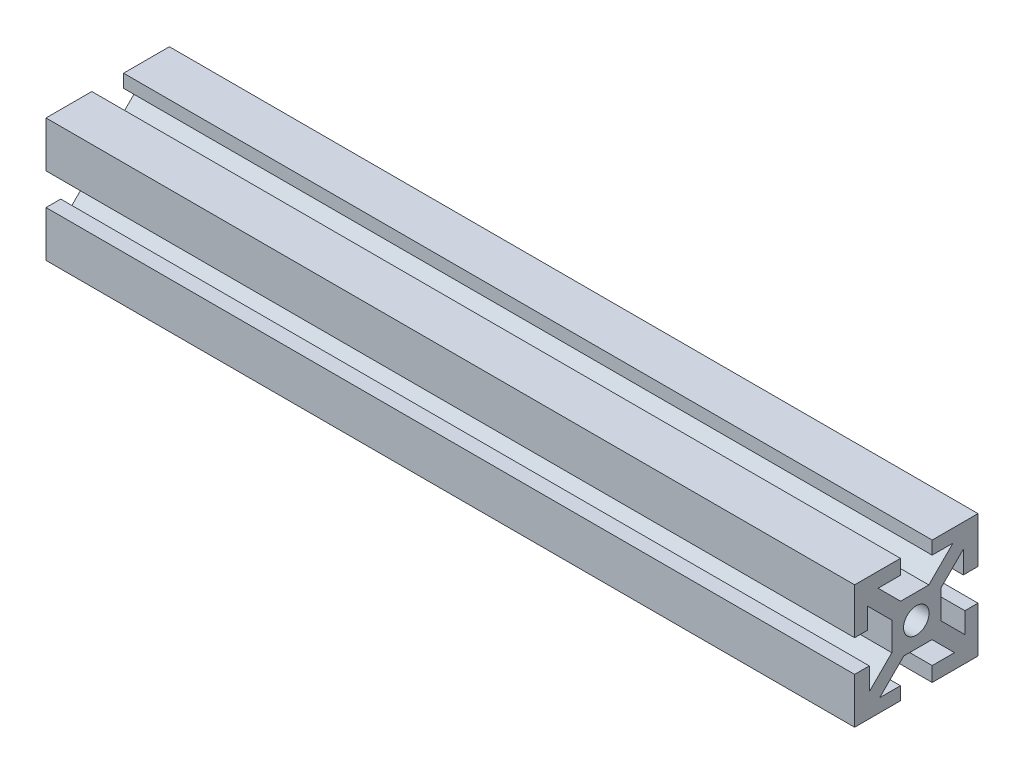
from build123d import *

# Parameters (mm, degrees)
SKETCH1_R           = 2.605
BOSS_EXTRUDE1_DEPTH = 165.1
CIRPATTERN1_COUNT   = 4
SKETCH2_R           = 2.38
CUT_EXTRUDE6_DEPTH  = 8


with BuildPart() as part:
    # Sketch1 → Boss-Extrude1 (new body)
    with BuildSketch(Plane(origin=(0, 0, 0), x_dir=(0, 0, -1), z_dir=(1, 0, 0))):
        Polygon((5, -5), (5, 3.203948776), (9.596194078, 7.800142853), (9.596194078, 3.24), (12.596194078, 3.24), (12.596194078, 12.596194078), (3.24, 12.596194078), (3.24, 9.921463197), (7.474873734, 9.921463197), (2.553410537, 5), (-5, 5), (-5, -5), align=None)
        Circle(SKETCH1_R, mode=Mode.SUBTRACT)
    boss_extrude1 = extrude(amount=BOSS_EXTRUDE1_DEPTH)

    # CirPattern1: Boss-Extrude1 ×4 about axis
    cirpattern1_axis = Axis((0, 0, 0), (1, 0, 0))
    for i in range(1, CIRPATTERN1_COUNT):
        add(boss_extrude1.rotate(cirpattern1_axis, i * 360 / CIRPATTERN1_COUNT))

    # Sketch2 → Cut-Extrude6 (cut)
    with BuildSketch(Plane.XY.offset(12.596194078)):
        with Locations((86.36, 0)):
            Circle(SKETCH2_R)
    extrude(amount=-CUT_EXTRUDE6_DEPTH, mode=Mode.SUBTRACT)


solid = part.part
